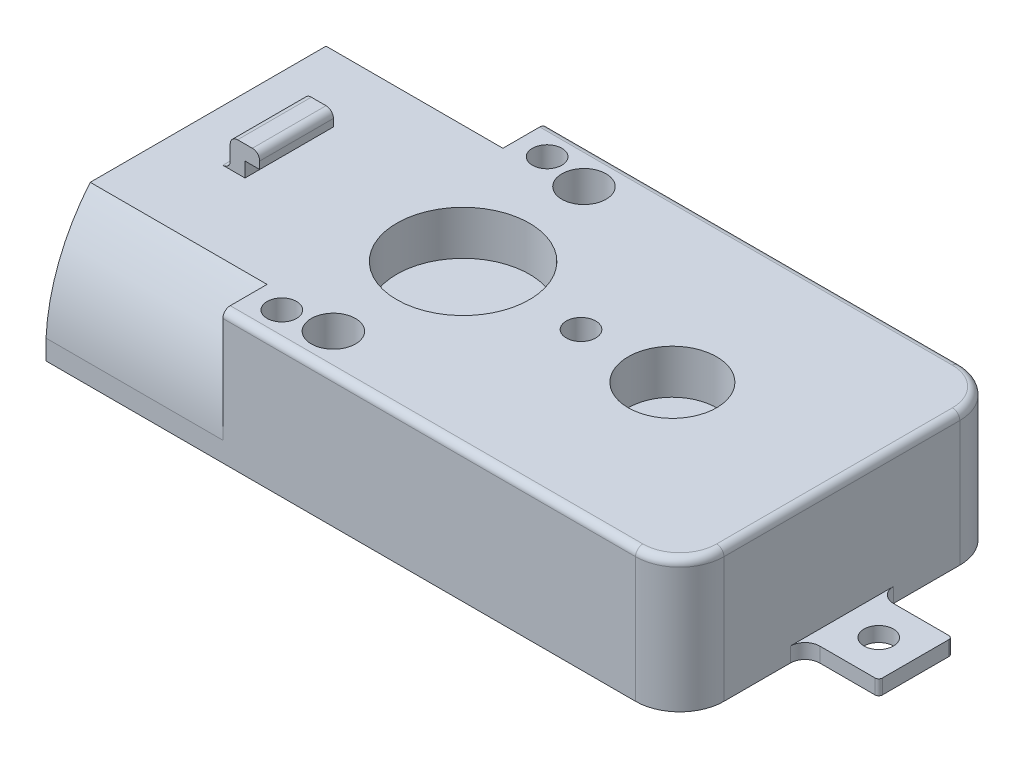
from build123d import *

# Parameters (mm, degrees)
BOSS_EXTRUDE2_DEPTH = 9
SKETCH4_W           = 5
SKETCH4_H           = 1
BOSS_EXTRUDE3_DEPTH = 5
SKETCH5_R           = 1
CUT_EXTRUDE1_DEPTH  = 5
FILLET1_R           = 1
FILLET2_R           = 1
FILLET3_R           = 3
FILLET4_R           = 3
BOSS_EXTRUDE4_DEPTH = 12
FILLET5_R           = 0.5
FILLET6_R           = 0.25
SKETCH8_R           = 3
CUT_EXTRUDE3_DEPTH  = 3
SKETCH9_R           = 0.75
CUT_EXTRUDE4_DEPTH  = 3
SKETCH10_R          = 1.5
CUT_EXTRUDE7_DEPTH  = 44.13930922
SKETCH12_R          = 1
CUT_EXTRUDE8_DEPTH  = 5
SKETCH13_W          = 1
SKETCH13_H          = 5
BOSS_EXTRUDE5_DEPTH = 2
SKETCH14_W          = 5
SKETCH14_H          = 1
BOSS_EXTRUDE6_DEPTH = 1
FILLET7_R           = 0.5
FILLET8_R           = 0.5
FILLET9_R           = 0.5
CUT_EXTRUDE9_DEPTH  = 10
SKETCH17_R          = 4.5
SKETCH17_R_2        = 1
CUT_EXTRUDE10_DEPTH = 3


with BuildPart() as part:
    # Sketch2 → Boss-Extrude2 (new body)
    with BuildSketch(Plane(origin=(0, 0, 0), x_dir=(1, 0, 0), z_dir=(0, 1, 0))):
        Polygon((0, 11), (31, 11), (31, 13.5), (31, 22), (0, 22), align=None)
        Polygon((31, 8.5), (31, 11), (0, 11), (0, 0), (31, 0), align=None)
    extrude(amount=BOSS_EXTRUDE2_DEPTH)

    # Sketch4 → Boss-Extrude3 (add)
    with BuildSketch(Plane(origin=(31, 0, 0), x_dir=(0, 0, -1), z_dir=(1, 0, 0))):
        with Locations((11, 0.5)):
            Rectangle(SKETCH4_W, SKETCH4_H)
    extrude(amount=BOSS_EXTRUDE3_DEPTH)

    # Sketch5 → Cut-Extrude1 (cut)
    with BuildSketch(Plane(origin=(0, 1, 0), x_dir=(1, 0, 0), z_dir=(0, 1, 0))):
        with Locations(Location((33.5, 11, 0), (0, 0, 270))):
            Circle(SKETCH5_R)
    extrude(amount=-CUT_EXTRUDE1_DEPTH, mode=Mode.SUBTRACT)

    # Fillet1
    fillet1_edges = [part.edges().sort_by_distance(p)[0] for p in [
        (31, 0.5, -8.5),
    ]]
    fillet(fillet1_edges, radius=FILLET1_R)

    # Fillet2
    fillet2_edges = [part.edges().sort_by_distance(p)[0] for p in [
        (31, 0.5, -13.5),
    ]]
    fillet(fillet2_edges, radius=FILLET2_R)

    # Fillet3
    fillet3_edges = [part.edges().sort_by_distance(p)[0] for p in [
        (31, 4.5, 0),
    ]]
    fillet(fillet3_edges, radius=FILLET3_R)

    # Fillet4
    fillet4_edges = [part.edges().sort_by_distance(p)[0] for p in [
        (31, 4.5, -22),
    ]]
    fillet(fillet4_edges, radius=FILLET4_R)

    # Sketch6 → Boss-Extrude4 (add)
    with BuildSketch(Plane.ZY):
        with BuildLine():
            Line((-22, 0), (-11, 0))
            Line((-11, 0), (-11, 9))
            Line((-11, 9), (-19, 9))
            ThreePointArc((-19, 9), (-21.121122912, 5.415884648), (-22, 1.344936316))
            Line((-22, 1.344936316), (-22, 0))
        make_face()
        with BuildLine():
            Line((-11, 9), (-11, 0))
            Line((-11, 0), (0, 0))
            Line((0, 0), (0, 1.344936316))
            ThreePointArc((0, 1.344936316), (-0.878877088, 5.415884648), (-3, 9))
            Line((-3, 9), (-11, 9))
        make_face()
    extrude(amount=BOSS_EXTRUDE4_DEPTH)

    # Fillet5
    fillet5_edges = [part.edges().sort_by_distance(p)[0] for p in [
        (14, 9, -22),
        (30.121320344, 9, -21.121320344),
        (31, 9, -11),
        (30.121320344, 9, -0.878679656),
        (14, 9, 0),
    ]]
    fillet(fillet5_edges, radius=FILLET5_R)

    # Fillet6
    fillet6_edges = [part.edges().sort_by_distance(p)[0] for p in [
        (36, 0.5, -13.5),
        (36, 0.5, -8.5),
    ]]
    fillet(fillet6_edges, radius=FILLET6_R)

    # Sketch8 → Cut-Extrude3 (cut)
    with BuildSketch(Plane(origin=(0, 9, 0), x_dir=(1, 0, 0), z_dir=(0, 1, 0))):
        with Locations(Location((19.5, 11, 0), (0, 0, 270))):
            Circle(SKETCH8_R)
    extrude(amount=-CUT_EXTRUDE3_DEPTH, mode=Mode.SUBTRACT)

    # Sketch9 → Cut-Extrude4 (cut)
    with BuildSketch(Plane(origin=(0, 6, 0), x_dir=(1, 0, 0), z_dir=(0, 1, 0))):
        with Locations(Location((19.5, 11, 0), (0, 0, 270))):
            Circle(SKETCH9_R)
    extrude(amount=-CUT_EXTRUDE4_DEPTH, mode=Mode.SUBTRACT)

    # Sketch10 → Cut-Extrude7 (cut, through all)
    with BuildSketch(Plane(origin=(0, 9, 0), x_dir=(1, 0, 0), z_dir=(0, 1, 0))):
        with Locations(Location((5, 19.5, 0), (0, 0, 90))):
            Circle(SKETCH10_R)
        with Locations(Location((5, 2.5, 0), (0, 0, 270))):
            Circle(SKETCH10_R)
    extrude(amount=-CUT_EXTRUDE7_DEPTH, mode=Mode.SUBTRACT)

    # Sketch12 → Cut-Extrude8 (cut)
    with BuildSketch(Plane(origin=(0, 9, 0), x_dir=(1, 0, 0), z_dir=(0, 1, 0))):
        with Locations(Location((2, 2, 0), (0, 0, 270))):
            Circle(SKETCH12_R)
        with Locations(Location((2, 20, 0), (0, 0, 270))):
            Circle(SKETCH12_R)
    extrude(amount=-CUT_EXTRUDE8_DEPTH, mode=Mode.SUBTRACT)

    # Sketch13 → Boss-Extrude5 (add)
    with BuildSketch(Plane(origin=(0, 9, 0), x_dir=(1, 0, 0), z_dir=(0, 1, 0))):
        with Locations((-7.5, 11)):
            Rectangle(SKETCH13_W, SKETCH13_H)
    extrude(amount=BOSS_EXTRUDE5_DEPTH)

    # Sketch14 → Boss-Extrude6 (add)
    with BuildSketch(Plane(origin=(-7, 0, 0), x_dir=(0, 0, -1), z_dir=(1, 0, 0))):
        with Locations((11, 10.5)):
            Rectangle(SKETCH14_W, SKETCH14_H)
    extrude(amount=BOSS_EXTRUDE6_DEPTH)

    # Fillet7
    fillet7_edges = [part.edges().sort_by_distance(p)[0] for p in [
        (-8, 11, -11),
    ]]
    fillet(fillet7_edges, radius=FILLET7_R)

    # Fillet8
    fillet8_edges = [part.edges().sort_by_distance(p)[0] for p in [
        (-8, 9, -11),
    ]]
    fillet(fillet8_edges, radius=FILLET8_R)

    # Fillet9
    fillet9_edges = [part.edges().sort_by_distance(p)[0] for p in [
        (-6, 11, -11),
    ]]
    fillet(fillet9_edges, radius=FILLET9_R)

    # Sketch16 → Cut-Extrude9 (cut)
    with BuildSketch(Plane.ZY.offset(12)):
        with BuildLine():
            Line((-18.232108037, 8.359420628), (-3.767891963, 8.359420628))
            ThreePointArc((-3.767891963, 8.359420628), (-1.809932353, 5.051006457), (-0.998661194, 1.293207997))
            Line((-0.998661194, 1.293207997), (-0.998661194, 0))
            Line((-0.998661194, 0), (-21, 0))
            Line((-21, 0), (-21.001338806, 1.293207997))
            ThreePointArc((-21.001338806, 1.293207997), (-20.190067647, 5.051006457), (-18.232108037, 8.359420628))
        make_face()
    extrude(amount=-CUT_EXTRUDE9_DEPTH, mode=Mode.SUBTRACT)

    # Sketch17 → Cut-Extrude10 (cut)
    with BuildSketch(Plane(origin=(0, 9, 0), x_dir=(1, 0, 0), z_dir=(0, 1, 0))):
        with Locations(Location((5.3, 11, 0), (0, 0, 270))):
            Circle(SKETCH17_R)
        with Locations(Location((13.3, 11, 0), (0, 0, 270))):
            Circle(SKETCH17_R_2)
    extrude(amount=-CUT_EXTRUDE10_DEPTH, mode=Mode.SUBTRACT)


solid = part.part
